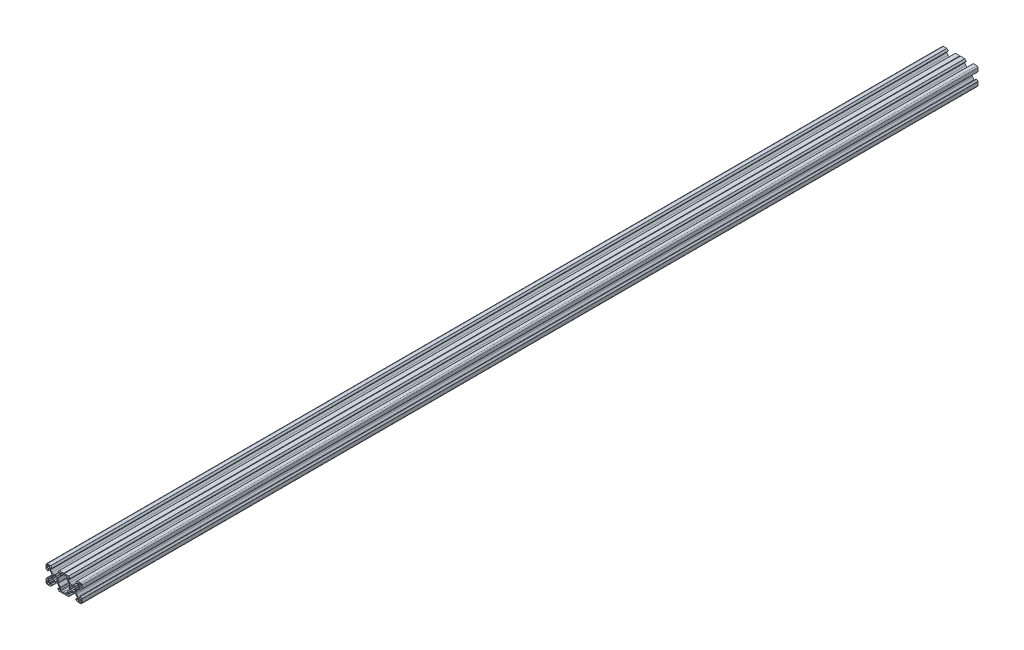
from build123d import *

# Parameters (mm, degrees)
EXTRUDE_1_DEPTH          = 1000
CUT_EXTRUDE_3_DEPTH      = 1000
SKETCH_14_W              = 3
SKETCH_14_H              = 3
CUT_EXTRUDE_5_DEPTH      = 1001.099995
FILLET_3_R               = 0.2
FILLET_7_R               = 2
CUT_EXTRUDE_4_DEPTH      = 1001.099995
FILLET_18_R              = 0.25
FILLET_19_R              = 0.25
FILLET_20_R              = 1
FILLET_22_R              = 0.25
SKETCH_18_R              = 0.7
CUT_EXTRUDE_7_DEPTH      = 1001.099995001
FILLET_25_R              = 0.25
FILLET_6_R               = 1.5
FILLET_23_R              = 0.25
CUT_EXTRUDE_6_DEPTH      = 1001.099995102
CUT_EXTRUDE_6_DEPTH_BACK = 1001.099995102
EXTRUDE_2_DEPTH          = 1000
FILLET_21_R              = 0.25
FILLET_24_R              = 0.6
EXTRUDE_3_DEPTH          = 1000


with BuildPart() as part:
    # Sketch 3 → Extrude 1 (new body)
    with BuildSketch(Plane.XY):
        with BuildLine():
            Line((-10, 10), (-3.08, 10))
            Line((-3.08, 10), (-3.08, 8))
            Line((-3.08, 8), (-5.2, 8))
            Line((-5.2, 8), (-5.2, 6.048528137))
            Line((-5.2, 6.048528137), (-2.651471863, 3.5))
            Line((-2.651471863, 3.5), (0, 3.5))
            Line((0, 3.5), (0, 2.5))
            ThreePointArc((0, 2.5), (-0.956708581, 2.309698831), (-1.767766953, 1.767766953))
            Line((-1.767766953, 1.767766953), (-10, 10))
        make_face()
    extrude(amount=-EXTRUDE_1_DEPTH)

    # Sketch 11 → Cut-Extrude 3 (cut)
    with BuildSketch(Plane.XY):
        Polygon((0, 3.5), (-0.25, 3.5), (0, 3.3), align=None)
    extrude(amount=-CUT_EXTRUDE_3_DEPTH, mode=Mode.SUBTRACT)

    # Sketch 14 → Cut-Extrude 5 (cut, through all)
    with BuildSketch(Plane.XY):
        with Locations((-7.6, 7.6)):
            Rectangle(SKETCH_14_W, SKETCH_14_H)
    extrude(amount=-CUT_EXTRUDE_5_DEPTH, mode=Mode.SUBTRACT)

    # Fillet 3
    fillet_3_edges = [part.edges().sort_by_distance(p)[0] for p in [
        (-5.2, 8, -500),
    ]]
    fillet(fillet_3_edges, radius=FILLET_3_R)

    # Fillet 7
    fillet_7_edges = [part.edges().sort_by_distance(p)[0] for p in [
        (-2.651471863, 3.5, -500),
    ]]
    fillet(fillet_7_edges, radius=FILLET_7_R)

    # Sketch 12 → Cut-Extrude 4 (cut, through all)
    with BuildSketch(Plane.XY):
        with BuildLine():
            Line((-3.153223305, 8.426776695), (-4.726446609, 10))
            Line((-4.726446609, 10), (-2.9, 10))
            Line((-2.9, 10), (-2.9, 8.353553391))
            Line((-2.9, 8.353553391), (-2.9, 7.9))
            Line((-2.9, 7.9), (-3.33, 7.9))
            Line((-3.33, 7.9), (-3.33, 8))
            ThreePointArc((-3.33, 8), (-3.099030117, 8.154329142), (-3.153223305, 8.426776695))
        make_face()
    extrude(amount=-CUT_EXTRUDE_4_DEPTH, mode=Mode.SUBTRACT)

    # Fillet 18
    fillet_18_edges = [part.edges().sort_by_distance(p)[0] for p in [
        (-4.726446609, 10, -500),
    ]]
    fillet(fillet_18_edges, radius=FILLET_18_R)

    # Fillet 19
    fillet_19_edges = [part.edges().sort_by_distance(p)[0] for p in [
        (-0.25, 3.5, -500),
    ]]
    fillet(fillet_19_edges, radius=FILLET_19_R)

    # Fillet 20
    fillet_20_edges = [part.edges().sort_by_distance(p)[0] for p in [
        (-5.2, 6.048528137, -500),
    ]]
    fillet(fillet_20_edges, radius=FILLET_20_R)

    # Fillet 22
    fillet_22_edges = [part.edges().sort_by_distance(p)[0] for p in [
        (-6.1, 9.1, -500),
    ]]
    fillet(fillet_22_edges, radius=FILLET_22_R)

    # Sketch 18 → Cut-Extrude 7 (cut, through all)
    with BuildSketch(Plane.XY):
        with Locations((-1.767766953, 1.767766953)):
            Circle(SKETCH_18_R)
    extrude(amount=-CUT_EXTRUDE_7_DEPTH, mode=Mode.SUBTRACT)

    # Fillet 25
    fillet_25_edges = [part.edges().sort_by_distance(p)[0] for p in [
        (-1.208370499, 2.188570478, -500),
    ]]
    fillet(fillet_25_edges, radius=FILLET_25_R)

    # Mirror 21: part across plane


with BuildPart() as part_1:
    add(part.part)
    add(part.part.mirror(Plane(origin=(-1.767766953, 1.767766953, -1000), x_dir=(0, 0, 1), z_dir=(-0.7071067811865476, -0.7071067811865476, 0))))

    # Fillet 6
    fillet_6_edges = [part_1.edges().sort_by_distance(p)[0] for p in [
        (-10, 10, -500),
    ]]
    fillet(fillet_6_edges, radius=FILLET_6_R)

    # Fillet 23
    fillet_23_edges = [part_1.edges().sort_by_distance(p)[0] for p in [
        (-6.1, 6.1, -500),
        (-9.1, 9.1, -500),
    ]]
    fillet(fillet_23_edges, radius=FILLET_23_R)

    # Mirror 25: part across plane


with BuildPart() as part_2:
    add(part_1.part)
    add(part_1.part.mirror(Plane(origin=(0, 3.5, -1000), x_dir=(0, 0, 1), z_dir=(1, 0, 0))))

    # Sketch 15 → Cut-Extrude 6 (cut, two sides)
    with BuildSketch(Plane.XY) as cut_extrude_6_sk:
        Polygon((3.5, 0), (3.5, 2.651471863), (6.1, 5.251471863), (6.1, 10), (10, 10), (10, 0), align=None)
    extrude(amount=CUT_EXTRUDE_6_DEPTH, mode=Mode.SUBTRACT)
    extrude(cut_extrude_6_sk.sketch, amount=-CUT_EXTRUDE_6_DEPTH_BACK, mode=Mode.SUBTRACT)

    # Sketch 13 → Extrude 2 (add)
    with BuildSketch(Plane.XY):
        with BuildLine():
            Line((0, 3.2), (0, 3.3))
            Line((0, 3.3), (0.25, 3.5))
            Line((0.25, 3.5), (2.651471863, 3.5))
            Line((2.651471863, 3.5), (5.2, 6.048528137))
            Line((5.2, 6.048528137), (5.2, 10))
            Line((5.2, 10), (9.7, 10))
            Line((9.7, 10), (10, 9.8))
            Line((10, 9.8), (10, 8.8))
            Line((10, 8.8), (6.3, 8.8))
            Line((6.3, 8.8), (6.3, 5.451471863))
            Line((6.3, 5.451471863), (3.5, 2.651471863))
            Line((3.5, 2.651471863), (3.5, 0))
            Line((3.5, 0), (3.2, 0))
            ThreePointArc((3.2, 0), (2.2627417, 2.2627417), (0, 3.2))
        make_face()
    extrude(amount=-EXTRUDE_2_DEPTH)

    # Fillet 21
    fillet_21_edges = [part_2.edges().sort_by_distance(p)[0] for p in [
        (0.25, 3.5, -500),
        (9.7, 10, -500),
    ]]
    fillet(fillet_21_edges, radius=FILLET_21_R)

    # Fillet 24
    fillet_24_edges = [part_2.edges().sort_by_distance(p)[0] for p in [
        (3.5, 2.651471863, -500),
        (6.3, 5.451471863, -500),
        (6.3, 8.8, -500),
    ]]
    fillet(fillet_24_edges, radius=FILLET_24_R)

    # Sketch 17 → Extrude 3 (add, through all)
    with BuildSketch(Plane.XY):
        with BuildLine():
            Line((10, 8.8), (10, 8.6))
            ThreePointArc((10, 8.6), (9.452277442, 8.650423759), (8.922967039, 8.8))
            Line((8.922967039, 8.8), (10, 8.8))
        make_face()
    extrude(amount=-EXTRUDE_3_DEPTH)

    # Mirror 22: part across plane


with BuildPart() as part_3:
    add(part_2.part)
    add(part_2.part.mirror(Plane(origin=(3.5, 0, -1000), x_dir=(0, 0, 1), z_dir=(0, -1, 0))))

    # Mirror 24: part across face


with BuildPart() as part_4:
    add(part_3.part)
    add(part_3.part.mirror(Plane(origin=(10, 9.2, -500), x_dir=(0, 0, 1), z_dir=(1, 0, 0))))


solid = part_4.part
